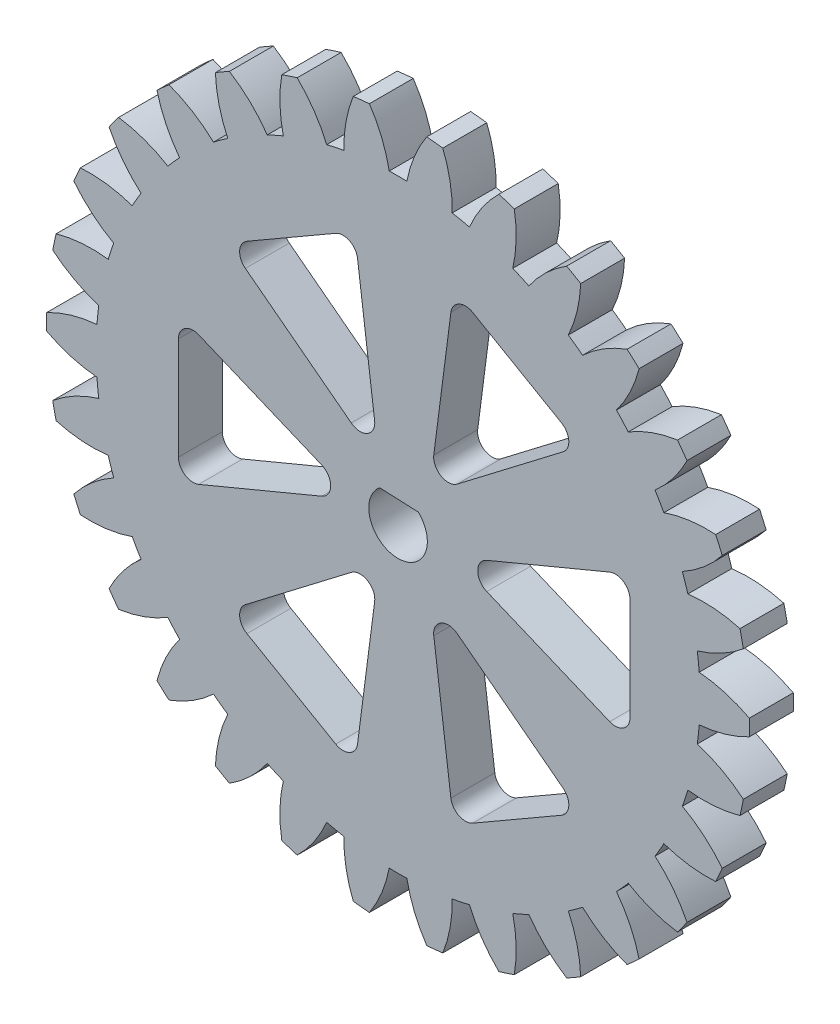
from build123d import *

# Parameters (mm, degrees)
SKETCH1_R                = 24
BOSS_EXTRUDE1_DEPTH      = 3
CUT_EXTRUDE1_DEPTH       = 4
CIRPATTERN1_COUNT        = 30
CUT_EXTRUDE2_DEPTH       = 4
FILLET5_R                = 1
FILLET6_R                = 1
FILLET7_R                = 1
CIRPATTERN4_COUNT        = 6
FILLET5_OF_CIRPATTERN4_R = 1
FILLET6_OF_CIRPATTERN4_R = 1
FILLET7_OF_CIRPATTERN4_R = 1
CUT_EXTRUDE3_DEPTH       = 4


with BuildPart() as part:
    # Sketch1 → Boss-Extrude1 (new body)
    with BuildSketch(Plane.XY):
        Circle(SKETCH1_R)
    extrude(amount=BOSS_EXTRUDE1_DEPTH)

    # Sketch2 → Cut-Extrude1 (cut, through all)
    with BuildSketch(Plane.XY.offset(3)):
        with BuildLine():
            ThreePointArc((-1.958050038, 23.919992476), (0, 24), (1.958050038, 23.919992476))
            ThreePointArc((1.958050038, 23.919992476), (1.114479195, 22.336043117), (0.60194016, 20.616214324))
            ThreePointArc((0.60194016, 20.616214324), (0, 20.625), (-0.60194016, 20.616214324))
            ThreePointArc((-0.60194016, 20.616214324), (-1.114479195, 22.336043117), (-1.958050038, 23.919992476))
        make_face()
    cut_extrude1 = extrude(amount=-CUT_EXTRUDE1_DEPTH, mode=Mode.SUBTRACT)

    # CirPattern1: Cut-Extrude1 ×30 about axis
    cirpattern1_axis = Axis((0, 0, 0), (0, 0, 1))
    for i in range(1, CIRPATTERN1_COUNT):
        add(cut_extrude1.rotate(cirpattern1_axis, i * 360 / CIRPATTERN1_COUNT), mode=Mode.SUBTRACT)

    # Sketch3 → Cut-Extrude2 (cut, through all)
    with BuildSketch(Plane.XY.offset(3)):
        Polygon((-3, 0), (-15, -5), (-15, 5), align=None)
    cut_extrude2 = extrude(amount=-CUT_EXTRUDE2_DEPTH, mode=Mode.SUBTRACT)

    # Fillet5
    fillet5_edges = [part.edges().sort_by_distance(p)[0] for p in [
        (-15, -5, 1.5),
    ]]
    fillet(fillet5_edges, radius=FILLET5_R)

    # Fillet6
    fillet6_edges = [part.edges().sort_by_distance(p)[0] for p in [
        (-15, 5, 1.5),
    ]]
    fillet(fillet6_edges, radius=FILLET6_R)

    # Fillet7
    fillet7_edges = [part.edges().sort_by_distance(p)[0] for p in [
        (-3, 0, 1.5),
    ]]
    fillet(fillet7_edges, radius=FILLET7_R)

    # CirPattern4: Cut-Extrude2 ×6 about axis
    cirpattern4_axis = Axis((0.421538775, 0, 0), (0, 0, 1))
    for i in range(1, CIRPATTERN4_COUNT):
        add(cut_extrude2.rotate(cirpattern4_axis, i * 360 / CIRPATTERN4_COUNT), mode=Mode.SUBTRACT)

    # Fillet5 of CirPattern4
    fillet5_of_cirpattern4_edges = [part.edges().sort_by_distance(p)[0] for p in [
        (-2.959103593, -15.855444345, 1.5),
        (12.462435182, -10.855444345, 1.5),
        (15.84307755, 5, 1.5),
        (3.802181144, 15.855444345, 1.5),
        (-11.619357631, 10.855444345, 1.5),
    ]]
    fillet(fillet5_of_cirpattern4_edges, radius=FILLET5_OF_CIRPATTERN4_R)

    # Fillet6 of CirPattern4
    fillet6_of_cirpattern4_edges = [part.edges().sort_by_distance(p)[0] for p in [
        (-11.619357631, -10.855444345, 1.5),
        (3.802181144, -15.855444345, 1.5),
        (15.84307755, -5, 1.5),
        (12.462435182, 10.855444345, 1.5),
        (-2.959103593, 15.855444345, 1.5),
    ]]
    fillet(fillet6_of_cirpattern4_edges, radius=FILLET6_OF_CIRPATTERN4_R)

    # Fillet7 of CirPattern4
    fillet7_of_cirpattern4_edges = [part.edges().sort_by_distance(p)[0] for p in [
        (-1.289230612, -2.963139499, 1.5),
        (2.132308163, -2.963139499, 1.5),
        (3.84307755, 0, 1.5),
        (2.132308163, 2.963139499, 1.5),
        (-1.289230612, 2.963139499, 1.5),
    ]]
    fillet(fillet7_of_cirpattern4_edges, radius=FILLET7_OF_CIRPATTERN4_R)

    # Sketch4 → Cut-Extrude3 (cut, through all)
    with BuildSketch(Plane.XY.offset(3)):
        with BuildLine():
            Line((-1.252642134, 1.559130426), (1.390321497, 1.437708641))
            ThreePointArc((1.390321497, 1.437708641), (-0.091786242, -1.997892711), (-1.252642134, 1.559130426))
        make_face()
    extrude(amount=-CUT_EXTRUDE3_DEPTH, mode=Mode.SUBTRACT)


solid = part.part
